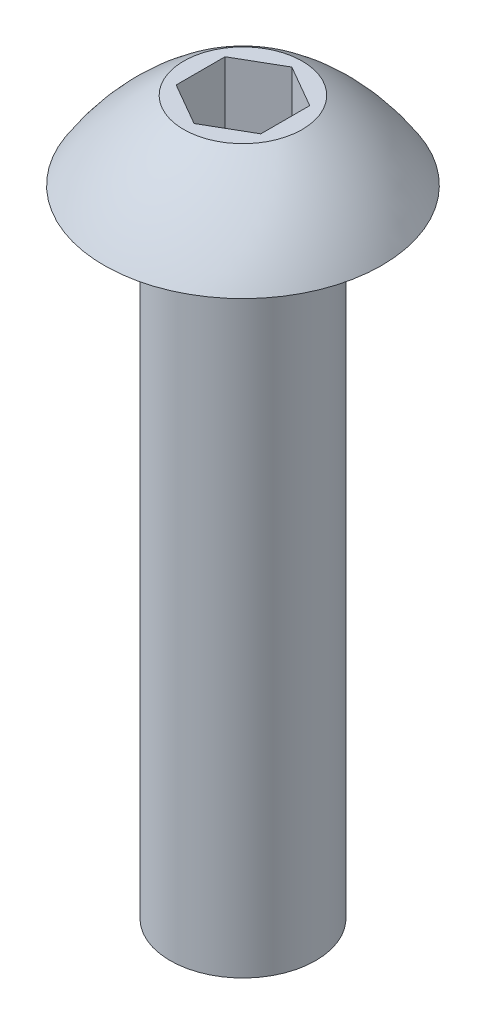
from build123d import *

# Parameters (mm, degrees)
CUT_EXTRUDE1_DEPTH = 1.27


with BuildPart() as part:
    # Sketch1 → Revolve1 (revolve)
    with BuildSketch(Plane.XY):
        with BuildLine():
            Line((-1.0922, 0), (-2.0828, 0))
            ThreePointArc((-2.0828, 0), (-1.555373888, 0.65518419), (-0.889, 1.1684))
            Line((-0.889, 1.1684), (0, 1.1684))
            Line((0, 1.1684), (0, -9.525))
            Line((0, -9.525), (-1.0922, -9.525))
            Line((-1.0922, -9.525), (-1.0922, 0))
        make_face()
    revolve(axis=Axis((0, -9.525, 0), (0, 1, 0)))

    # Sketch2 → Cut-Extrude1 (cut)
    with BuildSketch(Plane(origin=(0, 1.1684, 0), x_dir=(1, 0, 0), z_dir=(0, 1, 0))):
        Polygon((-0.635, 0.366617421), (-0.635, -0.366617421), (0, -0.733234842), (0.635, -0.366617421), (0.635, 0.366617421), (0, 0.733234842), align=None)
    extrude(amount=-CUT_EXTRUDE1_DEPTH, mode=Mode.SUBTRACT)


solid = part.part
